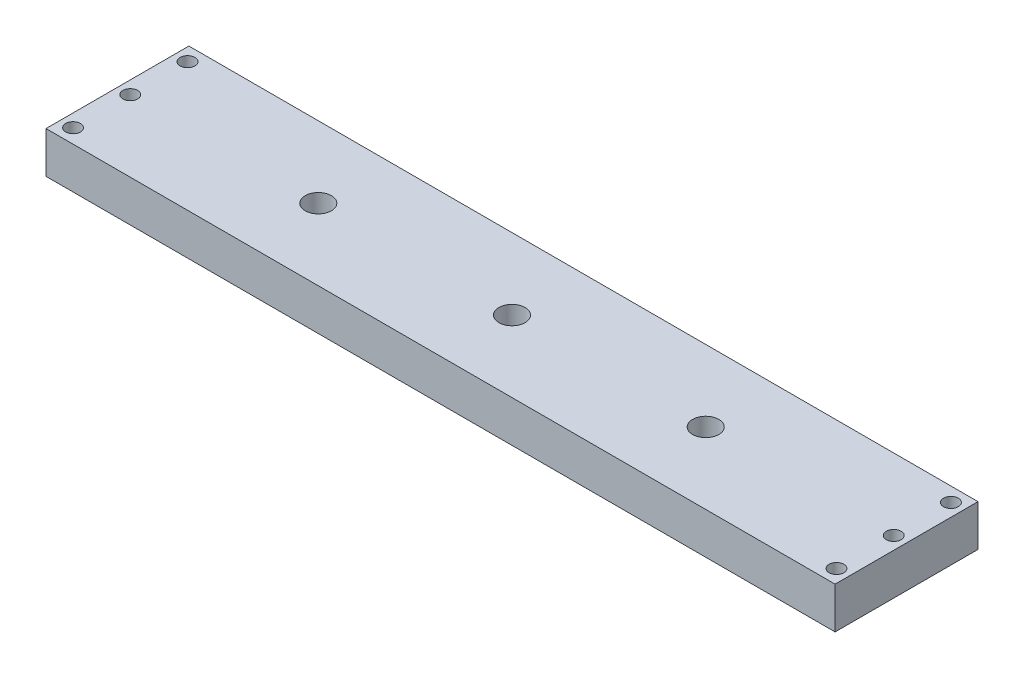
from build123d import *

# Parameters (mm, degrees)
SKETCH1_W           = 203.2
SKETCH1_H           = 36.79952
BOSS_EXTRUDE1_DEPTH = 10.668
SKETCH3_R           = 1.905
CUT_EXTRUDE1_DEPTH  = 11.668
SKETCH4_R           = 3.3782
CUT_EXTRUDE2_DEPTH  = 11.668


with BuildPart() as part:
    # Sketch1 → Boss-Extrude1 (new body)
    with BuildSketch(Plane(origin=(0, 0, 0), x_dir=(1, 0, 0), z_dir=(0, 1, 0))):
        Rectangle(SKETCH1_W, SKETCH1_H)
    extrude(amount=BOSS_EXTRUDE1_DEPTH)

    # Sketch3 → Cut-Extrude1 (cut, through all)
    with BuildSketch(Plane.XZ):
        with Locations((-98.298, 14.732)):
            Circle(SKETCH3_R)
        with Locations((-98.298, 0)):
            Circle(SKETCH3_R)
        with Locations((-98.298, -14.732)):
            Circle(SKETCH3_R)
    cut_extrude1 = extrude(amount=-CUT_EXTRUDE1_DEPTH, mode=Mode.SUBTRACT)

    # Mirror1: Cut-Extrude1 across plane
    add(cut_extrude1.mirror(Plane(origin=(0, 0, 0), x_dir=(0, 0, 1), z_dir=(1, 0, 0))), mode=Mode.SUBTRACT)

    # Sketch4 → Cut-Extrude2 (cut, through all)
    with BuildSketch(Plane(origin=(0, 10.668, 0), x_dir=(1, 0, 0), z_dir=(0, 1, 0))):
        with Locations((-49.8856, 0)):
            Circle(SKETCH4_R)
        Circle(SKETCH4_R)
        with Locations((49.8856, 0)):
            Circle(SKETCH4_R)
    extrude(amount=-CUT_EXTRUDE2_DEPTH, mode=Mode.SUBTRACT)


solid = part.part
